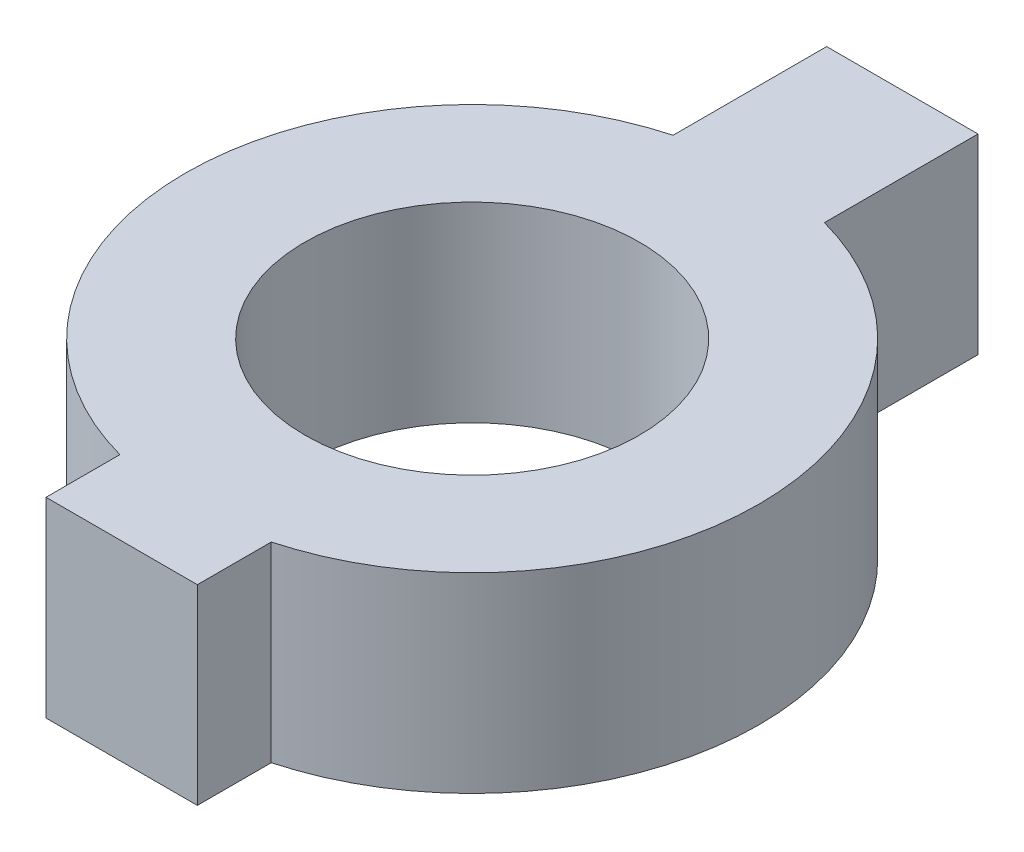
from build123d import *

# Parameters (mm, degrees)
ESQUISSE2_R        = 18
ESQUISSE2_R_2      = 10.5
BOSS_EXTRU_1_DEPTH = 12


with BuildPart() as part:
    # Esquisse2 → Boss.-Extru.1 (new body)
    with BuildSketch(Plane(origin=(0, 0, 0), x_dir=(1, 0, 0), z_dir=(0, 1, 0))):
        Circle(ESQUISSE2_R)
        with Locations(Location((0, 0, 0), (0, 0, 270))):  # turned: the seam where the file's is
            Circle(ESQUISSE2_R_2, mode=Mode.SUBTRACT)
        with BuildLine():
            Line((-4.75, -17.361955535), (-4.75, -22))
            Line((-4.75, -22), (4.75, -22))
            Line((4.75, -22), (4.75, -17.361955535))
            ThreePointArc((4.75, -17.361955535), (0, -18), (-4.75, -17.361955535))
        make_face()
        with BuildLine():
            Line((-4.75, 27), (-4.75, 17.361955535))
            ThreePointArc((-4.75, 17.361955535), (0, 18), (4.75, 17.361955535))
            Line((4.75, 17.361955535), (4.75, 27))
            Line((4.75, 27), (-4.75, 27))
        make_face()
    extrude(amount=BOSS_EXTRU_1_DEPTH)


solid = part.part
